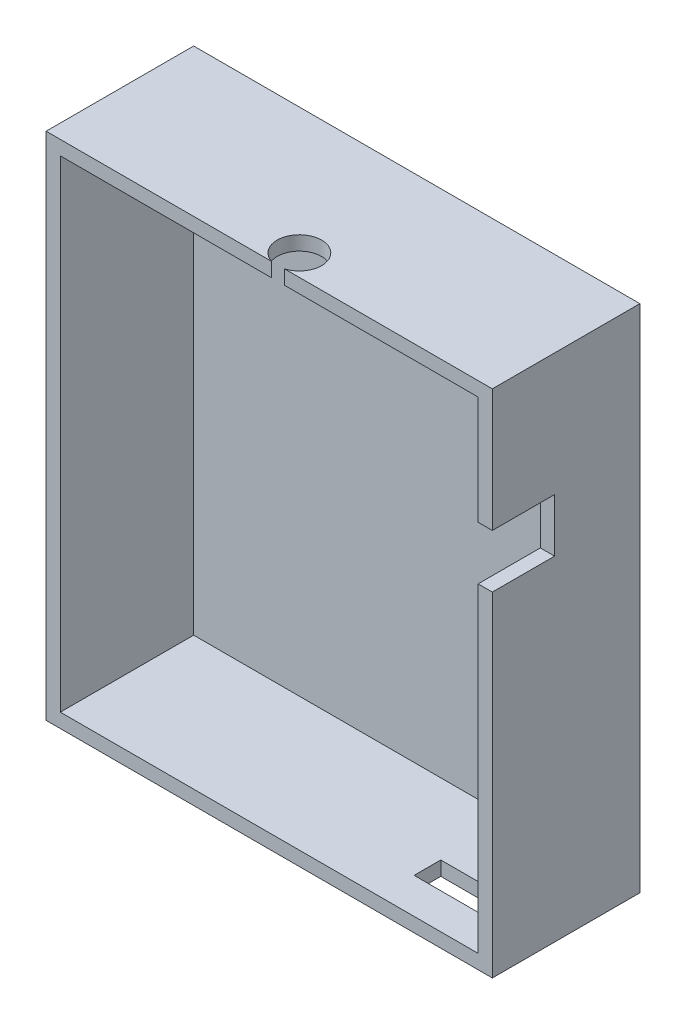
from build123d import *

# Parameters (mm, degrees)
SKETCH1_W           = 50.2
SKETCH1_H           = 57.4
BOSS_EXTRUDE1_DEPTH = 16.6
SHELL1_T            = -1.6
SKETCH2_W           = 8.6
SKETCH2_H           = 3
CUT_EXTRUDE1_DEPTH  = 16.6
SKETCH3_W           = 9.2
SKETCH3_H           = 6
CUT_EXTRUDE2_DEPTH  = 16.6
SKETCH4_R           = 2.5
CUT_EXTRUDE3_DEPTH  = 16.6


with BuildPart() as part:
    # Sketch1 → Boss-Extrude1 (new body)
    with BuildSketch(Plane.XY):
        with Locations((25.1, -5.901746725)):
            Rectangle(SKETCH1_W, SKETCH1_H)
    extrude(amount=BOSS_EXTRUDE1_DEPTH)

    # Shell1
    shell1_openings = [part.faces().sort_by_distance(p)[0] for p in [
        (25.1, -5.901746725, 16.6),
    ]]
    offset(amount=SHELL1_T, openings=shell1_openings, kind=Kind.INTERSECTION)

    # Sketch2 → Cut-Extrude1 (cut)
    with BuildSketch(Plane.XZ.offset(34.601746725)):
        with Locations((41.7, 11.1)):
            Rectangle(SKETCH2_W, SKETCH2_H)
    extrude(amount=-CUT_EXTRUDE1_DEPTH, mode=Mode.SUBTRACT)

    # Sketch3 → Cut-Extrude2 (cut)
    with BuildSketch(Plane(origin=(50.2, 0, 0), x_dir=(0, 0, -1), z_dir=(1, 0, 0))):
        with Locations((-14.2, 5.998253275)):
            Rectangle(SKETCH3_W, SKETCH3_H)
    extrude(amount=-CUT_EXTRUDE2_DEPTH, mode=Mode.SUBTRACT)

    # Sketch4 → Cut-Extrude3 (cut)
    with BuildSketch(Plane(origin=(0, 22.798253275, 0), x_dir=(1, 0, 0), z_dir=(0, 1, 0))):
        with Locations((26.1, -14.206462085)):
            Circle(SKETCH4_R)
    extrude(amount=-CUT_EXTRUDE3_DEPTH, mode=Mode.SUBTRACT)


solid = part.part
